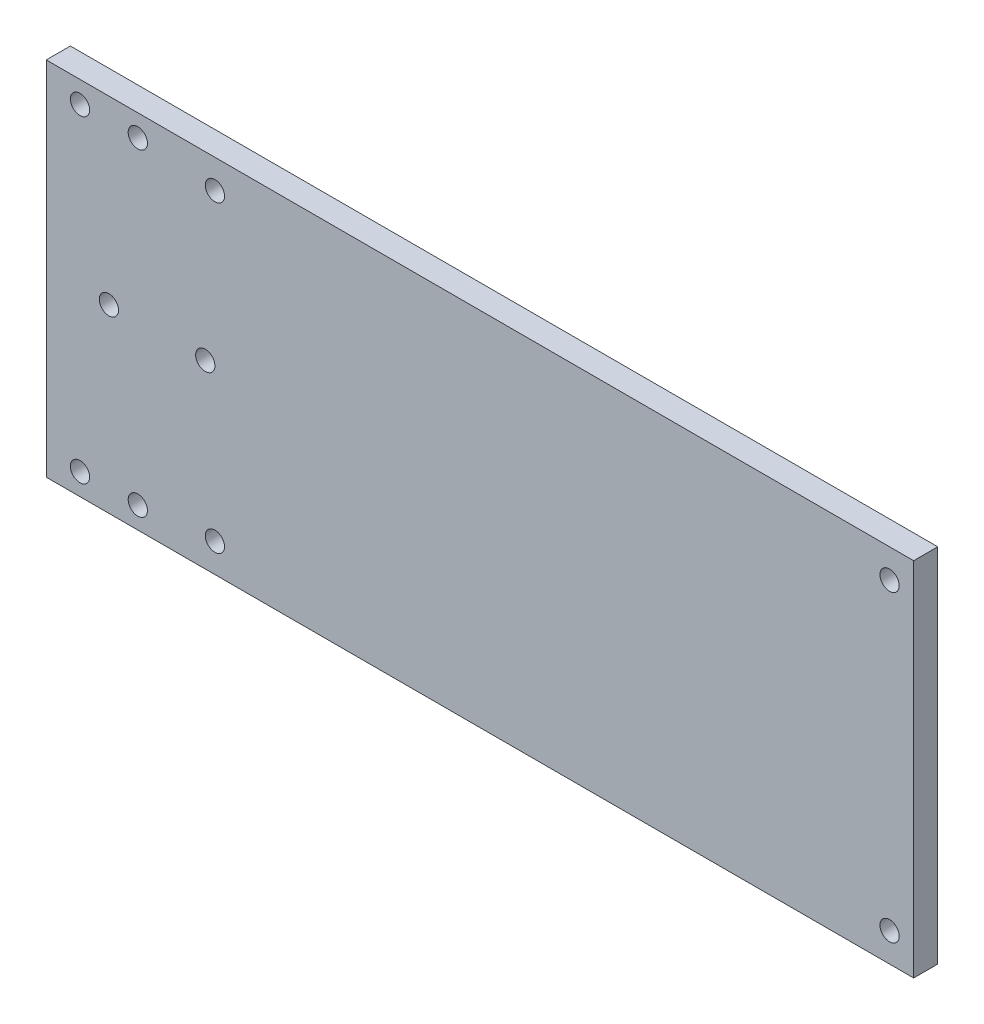
from build123d import *

# Parameters (mm, degrees)
ESBO_O1_W                = 180
ESBO_O1_H                = 75
ESBO_O1_R                = 2
RESSALTO_EXTRUS_O1_DEPTH = 5


with BuildPart() as part:
    # Esboço1 → Ressalto-extrusão1 (new body)
    with BuildSketch(Plane.XY):
        Rectangle(ESBO_O1_W, ESBO_O1_H)
        with Locations((-83, 33)):
            Circle(ESBO_O1_R, mode=Mode.SUBTRACT)
        with Locations((-71, 33)):
            Circle(ESBO_O1_R, mode=Mode.SUBTRACT)
        with Locations((-71, -33)):
            Circle(ESBO_O1_R, mode=Mode.SUBTRACT)
        with Locations((-77, 0)):
            Circle(ESBO_O1_R, mode=Mode.SUBTRACT)
        with Locations((-83, -33)):
            Circle(ESBO_O1_R, mode=Mode.SUBTRACT)
        with Locations((-57, 0)):
            Circle(ESBO_O1_R, mode=Mode.SUBTRACT)
        with Locations((-55, 31.5)):
            Circle(ESBO_O1_R, mode=Mode.SUBTRACT)
        with Locations((85, 31.5)):
            Circle(ESBO_O1_R, mode=Mode.SUBTRACT)
        with Locations((85, -31.5)):
            Circle(ESBO_O1_R, mode=Mode.SUBTRACT)
        with Locations((-55, -31.5)):
            Circle(ESBO_O1_R, mode=Mode.SUBTRACT)
    extrude(amount=RESSALTO_EXTRUS_O1_DEPTH)


solid = part.part
